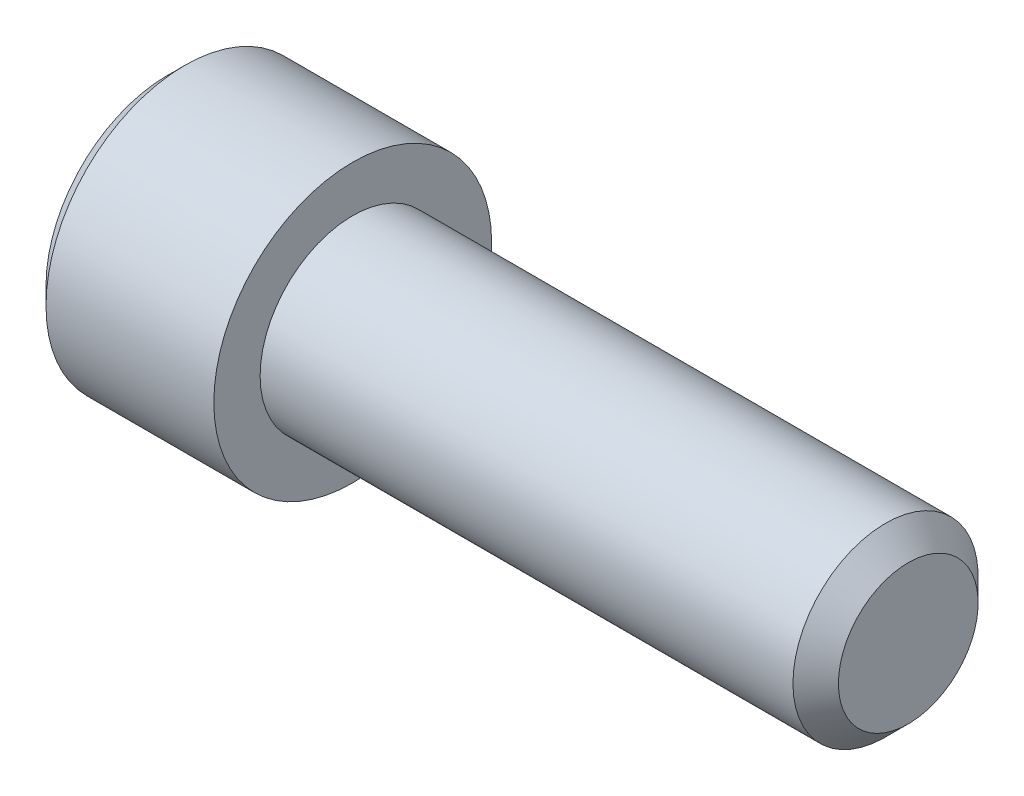
from build123d import *

# Parameters (mm, degrees)
CUT_EXTRUDE1_DEPTH = 1


with BuildPart() as part:
    # Sketch1 → Revolve1 (revolve)
    with BuildSketch(Plane.XY):
        Polygon((-2, 0), (-2, 1.3125), (-1.8125, 1.5), (0, 1.5), (0, 1), (5.7545, 1), (6, 0.7545), (6, 0), align=None)
    revolve(axis=Axis((6, 0, 0), (-1, 0, 0)))

    # Sketch2 → Cut-Revolve1 (revolve, cut)
    with BuildSketch(Plane.XY):
        Polygon((-2, 0), (-2, 0.9), (-1.85, 0.75), (-1, 0.75), (-0.6, 0), align=None)
    revolve(axis=Axis((-0.6, 0, 0), (-1, 0, 0)), mode=Mode.SUBTRACT)

    # Sketch3 → Cut-Extrude1 (cut)
    with BuildSketch(Plane(origin=(-2, 0, 0), x_dir=(0, 0, -1), z_dir=(1, 0, 0))):
        Polygon((-0.75, -0.433012702), (0, -0.866025404), (0.75, -0.433012702), (0.75, 0.433012702), (0, 0.866025404), (-0.75, 0.433012702), align=None)
    extrude(amount=CUT_EXTRUDE1_DEPTH, mode=Mode.SUBTRACT)


solid = part.part
